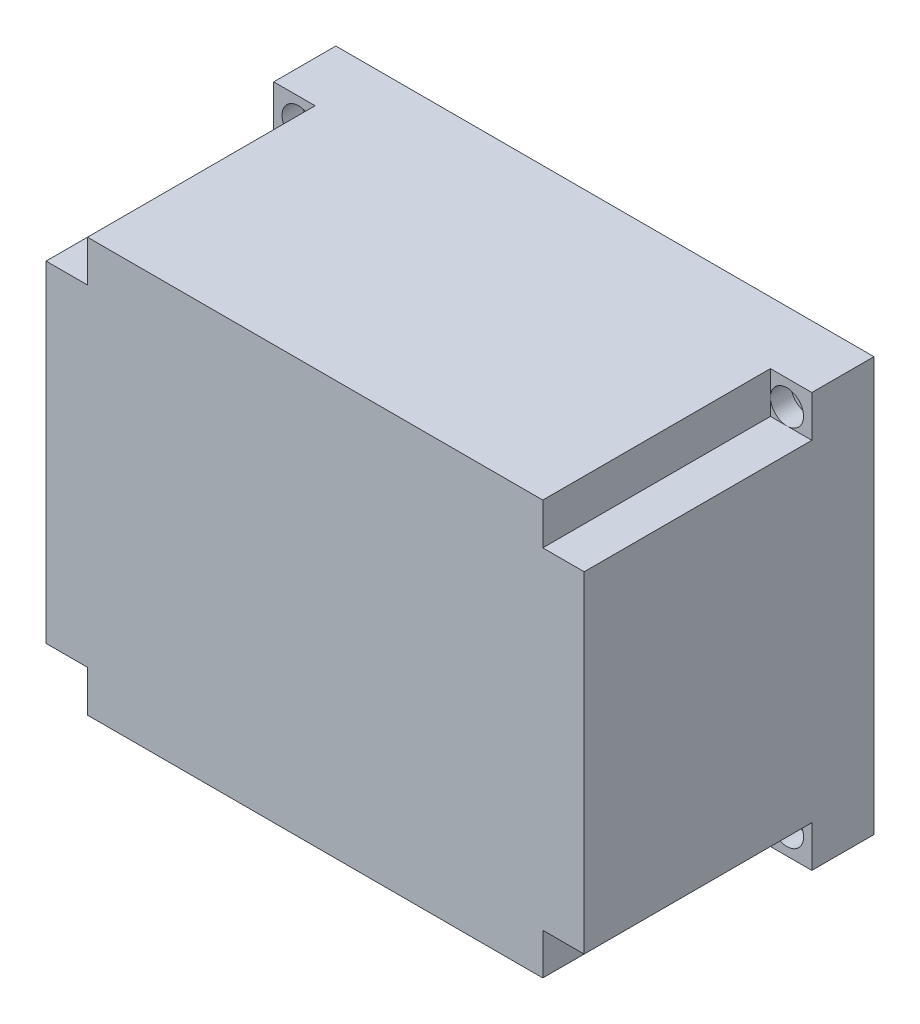
from build123d import *

# Parameters (mm, degrees)
SKETCH2_W           = 130
SKETCH2_H           = 70
BOSS_EXTRUDE1_DEPTH = 100
SKETCH3_W           = 104
SKETCH3_H           = 74
CUT_EXTRUDE1_DEPTH  = 67
SKETCH4_W           = 10
SKETCH4_H           = 10
CUT_EXTRUDE2_DEPTH  = 55
SKETCH5_W           = 104
SKETCH5_H           = 10
CUT_EXTRUDE3_DEPTH  = 67
SKETCH6_W           = 10
SKETCH6_H           = 74
CUT_EXTRUDE4_DEPTH  = 67
SKETCH9_R           = 1.75
CUT_EXTRUDE5_DEPTH  = 67
SKETCH10_R          = 4
CUT_EXTRUDE6_DEPTH  = 5
SKETCH12_R          = 4
CUT_EXTRUDE7_DEPTH  = 5
SKETCH13_R          = 4
CUT_EXTRUDE8_DEPTH  = 5
SKETCH14_R          = 4
CUT_EXTRUDE9_DEPTH  = 5
SKETCH15_W          = 3
SKETCH15_H          = 3
BOSS_EXTRUDE2_DEPTH = 5


with BuildPart() as part:
    # Sketch2 → Boss-Extrude1 (new body)
    with BuildSketch(Plane(origin=(0, 0, 0), x_dir=(1, 0, 0), z_dir=(0, 1, 0))):
        with Locations((65, 35)):
            Rectangle(SKETCH2_W, SKETCH2_H)
    extrude(amount=BOSS_EXTRUDE1_DEPTH)

    # Sketch3 → Cut-Extrude1 (cut)
    with BuildSketch(Plane(origin=(0, 0, -70), x_dir=(-1, 0, 0), z_dir=(0, 0, -1))):
        with Locations((-65, 50)):
            Rectangle(SKETCH3_W, SKETCH3_H)
    extrude(amount=-CUT_EXTRUDE1_DEPTH, mode=Mode.SUBTRACT)

    # Sketch4 → Cut-Extrude2 (cut)
    with BuildSketch(Plane.XY):
        with Locations((5, 95)):
            Rectangle(SKETCH4_W, SKETCH4_H)
        with Locations((125, 95)):
            Rectangle(SKETCH4_W, SKETCH4_H)
        with Locations((5, 5)):
            Rectangle(SKETCH4_W, SKETCH4_H)
        with Locations((125, 5)):
            Rectangle(SKETCH4_W, SKETCH4_H)
    extrude(amount=-CUT_EXTRUDE2_DEPTH, mode=Mode.SUBTRACT)

    # Sketch5 → Cut-Extrude3 (cut)
    with BuildSketch(Plane(origin=(0, 0, -70), x_dir=(-1, 0, 0), z_dir=(0, 0, -1))):
        with Locations((-65, 92)):
            Rectangle(SKETCH5_W, SKETCH5_H)
        with Locations((-65, 8)):
            Rectangle(SKETCH5_W, SKETCH5_H)
    extrude(amount=-CUT_EXTRUDE3_DEPTH, mode=Mode.SUBTRACT)

    # Sketch6 → Cut-Extrude4 (cut)
    with BuildSketch(Plane(origin=(0, 0, -70), x_dir=(-1, 0, 0), z_dir=(0, 0, -1))):
        with Locations((-122, 50)):
            Rectangle(SKETCH6_W, SKETCH6_H)
        with Locations((-8, 50)):
            Rectangle(SKETCH6_W, SKETCH6_H)
    extrude(amount=-CUT_EXTRUDE4_DEPTH, mode=Mode.SUBTRACT)

    # Sketch9 → Cut-Extrude5 (cut)
    with BuildSketch(Plane(origin=(0, 0, -70), x_dir=(-1, 0, 0), z_dir=(0, 0, -1))):
        with Locations((-124, 94)):
            Circle(SKETCH9_R)
        with Locations((-124, 6)):
            Circle(SKETCH9_R)
        with Locations((-6, 94)):
            Circle(SKETCH9_R)
        with Locations((-6, 6)):
            Circle(SKETCH9_R)
    extrude(amount=-CUT_EXTRUDE5_DEPTH, mode=Mode.SUBTRACT)

    # Sketch10 → Cut-Extrude6 (cut)
    with BuildSketch(Plane.XY.offset(-55)):
        with Locations((124, 94)):
            Circle(SKETCH10_R)
    extrude(amount=-CUT_EXTRUDE6_DEPTH, mode=Mode.SUBTRACT)

    # Sketch12 → Cut-Extrude7 (cut)
    with BuildSketch(Plane.XY.offset(-55)):
        with Locations((124, 6)):
            Circle(SKETCH12_R)
    extrude(amount=-CUT_EXTRUDE7_DEPTH, mode=Mode.SUBTRACT)

    # Sketch13 → Cut-Extrude8 (cut)
    with BuildSketch(Plane.XY.offset(-55)):
        with Locations((6, 6)):
            Circle(SKETCH13_R)
    extrude(amount=-CUT_EXTRUDE8_DEPTH, mode=Mode.SUBTRACT)

    # Sketch14 → Cut-Extrude9 (cut)
    with BuildSketch(Plane.XY.offset(-55)):
        with Locations((6, 94)):
            Circle(SKETCH14_R)
    extrude(amount=-CUT_EXTRUDE9_DEPTH, mode=Mode.SUBTRACT)

    # Sketch15 → Boss-Extrude2 (add)
    with BuildSketch(Plane(origin=(0, 0, -70), x_dir=(-1, 0, 0), z_dir=(0, 0, -1))):
        with Locations((-118.5, 88.5)):
            Rectangle(SKETCH15_W, SKETCH15_H)
        with Locations((-118.5, 11.5)):
            Rectangle(SKETCH15_W, SKETCH15_H)
        with Locations((-11.5, 11.5)):
            Rectangle(SKETCH15_W, SKETCH15_H)
        with Locations((-11.5, 88.5)):
            Rectangle(SKETCH15_W, SKETCH15_H)
    extrude(amount=BOSS_EXTRUDE2_DEPTH)


solid = part.part
